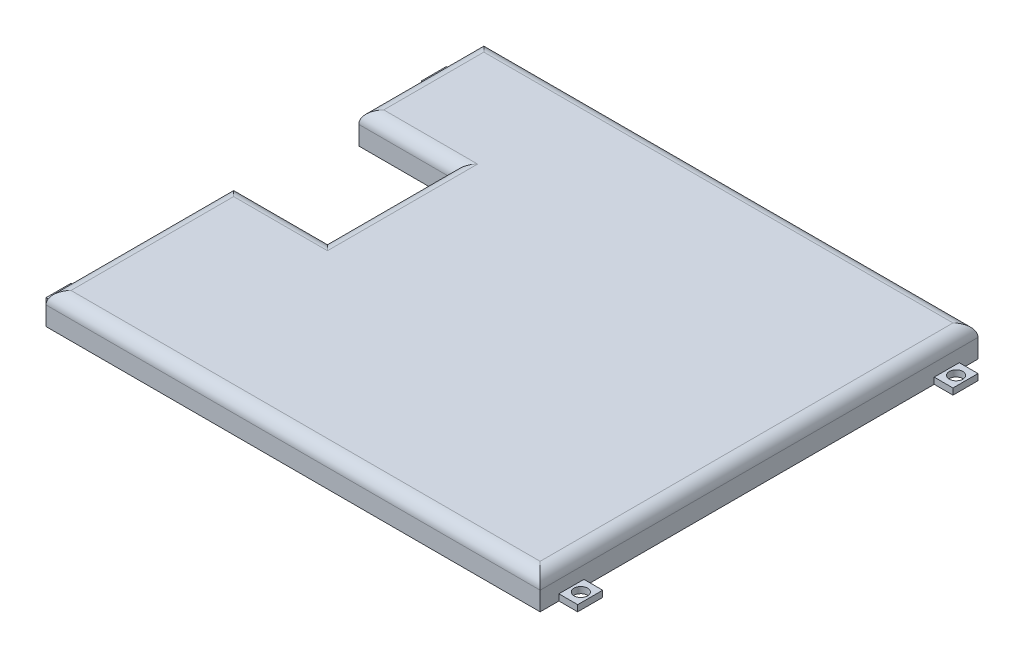
from build123d import *

# Parameters (mm, degrees)
BOSS_EXTRUDE1_DEPTH  = 5
SKETCH3_W            = 4
SKETCH3_H            = 5
BOSS_EXTRUDE2_DEPTH  = 3
SKETCH4_R            = 1.08
CUT_EXTRUDE1_DEPTH   = 6
LPATTERN1_COUNT      = 2
LPATTERN1_PITCH      = 60
LPATTERN1_COUNT_DIR2 = 2
LPATTERN1_PITCH_DIR2 = 82
LPATTERN2_COUNT      = 2
LPATTERN2_PITCH      = 60
LPATTERN2_COUNT_DIR2 = 2
LPATTERN2_PITCH_DIR2 = 82
SKETCH5_W            = 3
SKETCH5_H            = 4
CUT_EXTRUDE2_DEPTH   = 4
CUT_EXTRUDE3_DEPTH   = 4
FILLET1_R            = 2


with BuildPart() as part:
    # Sketch2 → Boss-Extrude1 (new body)
    with BuildSketch(Plane(origin=(0, 0, 0), x_dir=(1, 0, 0), z_dir=(0, 1, 0))):
        Polygon((0, 0), (79, 0), (79, 70), (0, 70), (0, 50), (15, 50), (15, 30), (0, 30), align=None)
    extrude(amount=BOSS_EXTRUDE1_DEPTH)

    # Sketch3 → Boss-Extrude2 (add)
    with BuildSketch(Plane(origin=(79, 0, 0), x_dir=(0, 0, -1), z_dir=(1, 0, 0))):
        with Locations((5, 2.5)):
            Rectangle(SKETCH3_W, SKETCH3_H)
    boss_extrude2 = extrude(amount=BOSS_EXTRUDE2_DEPTH)

    # Sketch4 → Cut-Extrude1 (cut, through all)
    with BuildSketch(Plane(origin=(0, 5, 0), x_dir=(1, 0, 0), z_dir=(0, 1, 0))):
        with Locations((80.5, 5)):
            Circle(SKETCH4_R)
    cut_extrude1 = extrude(amount=-CUT_EXTRUDE1_DEPTH, mode=Mode.SUBTRACT)

    # LPattern1: Boss-Extrude2 2 × 2
    with Locations(*[(-j * LPATTERN1_PITCH_DIR2, 0, -i * LPATTERN1_PITCH) for i in range(LPATTERN1_COUNT) for j in range(LPATTERN1_COUNT_DIR2) if (i, j) != (0, 0)]):
        add(boss_extrude2)

    # LPattern2: Cut-Extrude1 2 × 2
    with Locations(*[(-j * LPATTERN2_PITCH_DIR2, 0, -i * LPATTERN2_PITCH) for i in range(LPATTERN2_COUNT) for j in range(LPATTERN2_COUNT_DIR2) if (i, j) != (0, 0)]):
        add(cut_extrude1, mode=Mode.SUBTRACT)

    # Sketch5 → Cut-Extrude2 (cut)
    with BuildSketch(Plane(origin=(0, 5, 0), x_dir=(1, 0, 0), z_dir=(0, 1, 0))):
        with Locations((-1.5, 65)):
            Rectangle(SKETCH5_W, SKETCH5_H)
        with Locations((-1.5, 5)):
            Rectangle(SKETCH5_W, SKETCH5_H)
        with Locations((80.5, 5)):
            Rectangle(SKETCH5_W, SKETCH5_H)
        with Locations((80.5, 65)):
            Rectangle(SKETCH5_W, SKETCH5_H)
    extrude(amount=-CUT_EXTRUDE2_DEPTH, mode=Mode.SUBTRACT)

    # Sketch7 → Cut-Extrude3 (cut)
    with BuildSketch(Plane.XZ):
        Polygon((2, -2), (77, -2), (77, -68), (2, -68), (2, -52), (17, -52), (17, -28), (2, -28), align=None)
    extrude(amount=-CUT_EXTRUDE3_DEPTH, mode=Mode.SUBTRACT)

    # Fillet1
    fillet1_edges = [part.edges().sort_by_distance(p)[0] for p in [
        (79, 5, -35),
        (39.5, 5, -70),
        (0, 5, -60),
        (7.5, 5, -50),
        (15, 5, -40),
        (7.5, 5, -30),
        (0, 5, -15),
        (39.5, 5, 0),
    ]]
    fillet(fillet1_edges, radius=FILLET1_R)


solid = part.part
